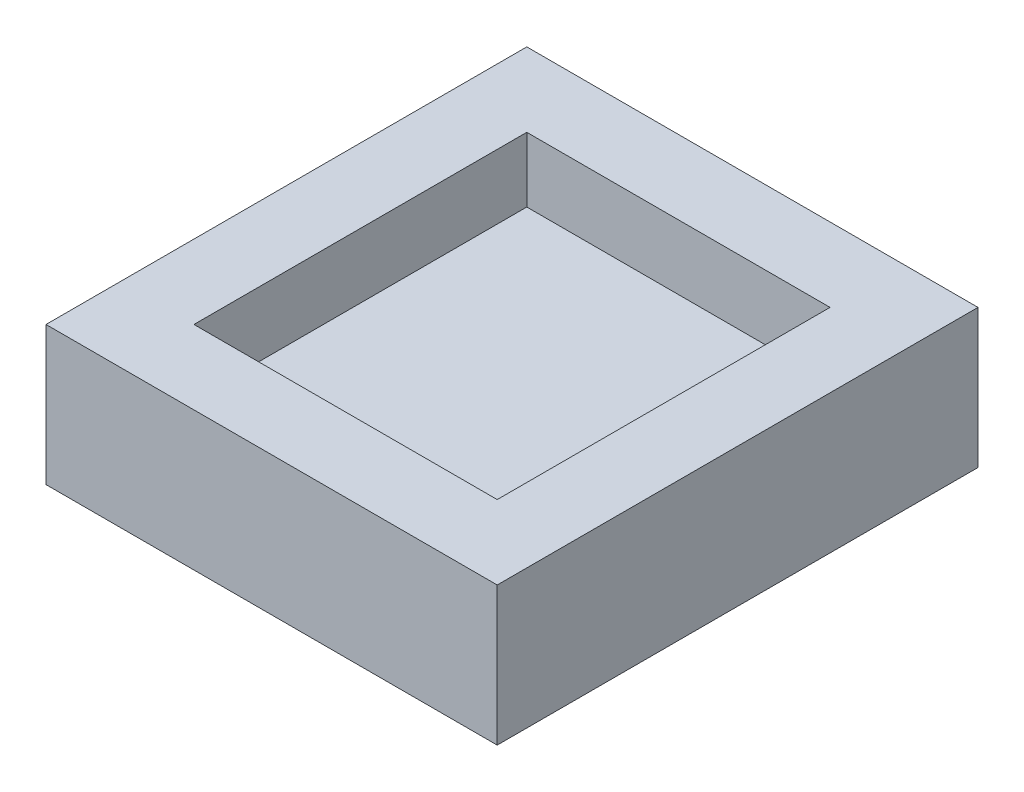
from build123d import *

# Parameters (mm, degrees)
SKETCH1_W           = 61
SKETCH1_H           = 65
BOSS_EXTRUDE1_DEPTH = 18.75
SKETCH2_W           = 41
SKETCH2_H           = 45
CUT_EXTRUDE1_DEPTH  = 8.75


with BuildPart() as part:
    # Sketch1 → Boss-Extrude1 (new body)
    with BuildSketch(Plane(origin=(0, 0, 0), x_dir=(1, 0, 0), z_dir=(0, 1, 0))):
        Rectangle(SKETCH1_W, SKETCH1_H)
    extrude(amount=BOSS_EXTRUDE1_DEPTH)

    # Sketch2 → Cut-Extrude1 (cut)
    with BuildSketch(Plane(origin=(0, 18.75, 0), x_dir=(1, 0, 0), z_dir=(0, 1, 0))):
        Rectangle(SKETCH2_W, SKETCH2_H)
    extrude(amount=-CUT_EXTRUDE1_DEPTH, mode=Mode.SUBTRACT)


solid = part.part
